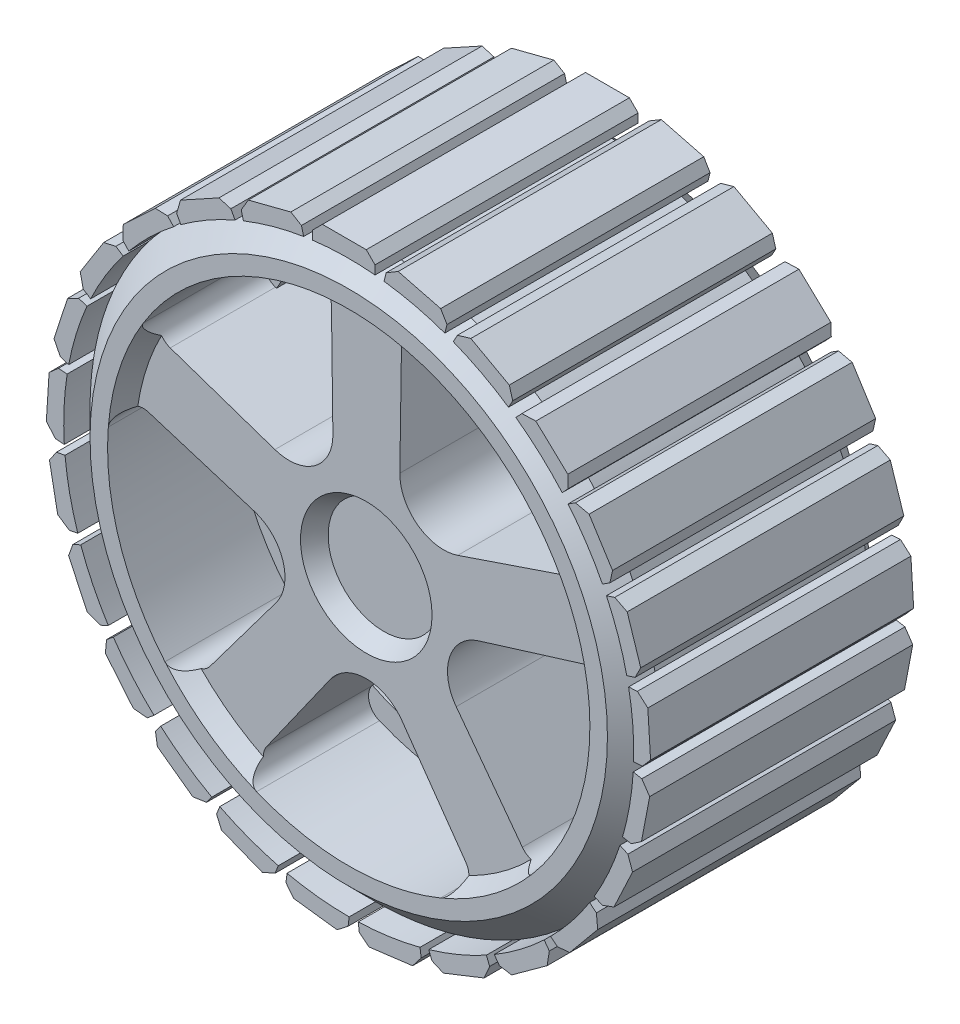
from build123d import *

# Parameters (mm, degrees)
SKETCH1_R           = 32.5
BOSS_EXTRUDE1_DEPTH = 15
CUT_EXTRUDE1_DEPTH  = 31
FILLET1_R           = 2
SKETCH5_R           = 27.5
CUT_EXTRUDE2_DEPTH  = 2
CUT_EXTRUDE2_TAPER  = 30
SKETCH7_R           = 7.5
CUT_EXTRUDE3_DEPTH  = 2
CUT_EXTRUDE3_TAPER  = 30
CHAMFER1_SIZE       = 3
SKETCH9_R           = 30
SKETCH9_R_2         = 25
BOSS_EXTRUDE2_DEPTH = 1
BOSS_EXTRUDE3_DEPTH = 15
SKETCH11_R          = 5
BOSS_EXTRUDE4_DEPTH = 4
SKETCH12_R          = 3
CUT_EXTRUDE4_DEPTH  = 10


with BuildPart() as part:
    # Sketch1 → Boss-Extrude1 (new body, symmetric)
    with BuildSketch(Plane.XY):
        Circle(SKETCH1_R)
    extrude(amount=BOSS_EXTRUDE1_DEPTH, both=True)

    # Sketch3 → Cut-Extrude1 (cut, through all)
    with BuildSketch(Plane.XY.offset(15)):
        with BuildLine():
            ThreePointArc((-4, 27.207535721), (-16.144447194, 22.262228657), (-24.618236097, 12.255302993))
            Line((-24.618236097, 12.255302993), (-10.420721182, 7.410922649))
            ThreePointArc((-10.420721182, 7.410922649), (-5.870708071, 8.095355875), (-3.806478173, 12.207535721))
            Line((-3.806478173, 12.207535721), (-4, 27.207535721))
        make_face()
        with BuildLine():
            Line((-12.786322839, 0.152160127), (-27.111972117, 4.603364848))
            ThreePointArc((-27.111972117, 4.603364848), (-26.16154618, -8.474874719), (-19.262939097, -19.626236964))
            Line((-19.262939097, -19.626236964), (-10.268386216, -7.620593742))
            ThreePointArc((-10.268386216, -7.620593742), (-9.51328952, -3.081772625), (-12.786322839, 0.152160127))
        make_face()
        with BuildLine():
            Line((-4.095903933, -12.113495591), (-12.75612027, -24.362499782))
            ThreePointArc((-12.75612027, -24.362499782), (-0.024277543, -27.499989284), (12.713085012, -24.384984508))
            Line((12.713085012, -24.384984508), (4.074509491, -12.120708596))
            ThreePointArc((4.074509491, -12.120708596), (-0.008828197, -9.999996103), (-4.095903933, -12.113495591))
        make_face()
        with BuildLine():
            ThreePointArc((27.5, 0), (27.404849824, 2.285652233), (27.120057736, 4.555487723))
            Line((27.120057736, 4.555487723), (12.786571569, 0.129583862))
            ThreePointArc((12.786571569, 0.129583862), (9.507833394, -3.098564854), (10.254914994, -7.638712124))
            Line((10.254914994, -7.638712124), (19.228256225, -19.660217764))
            ThreePointArc((19.228256225, -19.660217764), (25.347850463, -10.664730512), (27.5, 0))
        make_face()
        with BuildLine():
            ThreePointArc((24.639836162, 12.211816978), (16.183729084, 22.233688694), (4.048032445, 27.200430756))
            Line((4.048032445, 27.200430756), (3.828026338, 12.200795827))
            ThreePointArc((3.828026338, 12.200795827), (5.884992394, 8.084977707), (10.433789951, 7.392511868))
            Line((10.433789951, 7.392511868), (24.639836162, 12.211816978))
        make_face()
    extrude(amount=-CUT_EXTRUDE1_DEPTH, mode=Mode.SUBTRACT)

    # Fillet1
    fillet1_edges = [part.edges().sort_by_distance(p)[0] for p in [
        (12.713085012, -24.384984508, 0),
        (-12.75612027, -24.362499782, 0),
        (-19.262939097, -19.626236964, 0),
        (-27.111972117, 4.603364848, 0),
        (27.120057736, 4.555487723, 0),
        (19.228256225, -19.660217764, 0),
        (4.048032445, 27.200430756, 0),
        (24.639836162, 12.211816978, 0),
        (-24.618236097, 12.255302993, 0),
        (-4, 27.207535721, 0),
    ]]
    fillet(fillet1_edges, radius=FILLET1_R)

    # Sketch5 → Cut-Extrude2 (cut)
    with BuildSketch(Plane.XY.offset(15)):
        Circle(SKETCH5_R)
    cut_extrude2 = extrude(amount=-CUT_EXTRUDE2_DEPTH, taper=CUT_EXTRUDE2_TAPER, mode=Mode.SUBTRACT)

    # Sketch7 → Cut-Extrude3 (cut)
    with BuildSketch(Plane.XY.offset(13)):
        Circle(SKETCH7_R)
    cut_extrude3 = extrude(amount=-CUT_EXTRUDE3_DEPTH, taper=CUT_EXTRUDE3_TAPER, mode=Mode.SUBTRACT)

    # Mirror1: Cut-Extrude2, Cut-Extrude3 across plane
    add(cut_extrude2.mirror(Plane.XY), mode=Mode.SUBTRACT)
    add(cut_extrude3.mirror(Plane.XY), mode=Mode.SUBTRACT)

    # Chamfer1
    chamfer1_edges = [part.edges().sort_by_distance(p)[0] for p in [
        (-32.5, 0, -15),
        (-32.5, 0, 15),
    ]]
    chamfer(chamfer1_edges, length=CHAMFER1_SIZE)

    # Sketch9 → Boss-Extrude2 (add, symmetric)
    with BuildSketch(Plane.XY):
        Circle(SKETCH9_R)
        Circle(SKETCH9_R_2, mode=Mode.SUBTRACT)
    extrude(amount=BOSS_EXTRUDE2_DEPTH, both=True)

    # Sketch10 → Boss-Extrude3 (add, symmetric)
    with BuildSketch(Plane.XY):
        with BuildLine():
            Line((-4.12394956, 32.237292691), (-4.12394956, 33.237292691))
            Line((-4.12394956, 33.237292691), (-3, 34.361242251))
            Line((-3, 34.361242251), (2, 34.361242251))
            Line((2, 34.361242251), (3, 33.361242251))
            Line((3, 33.361242251), (3, 32.361242251))
            ThreePointArc((3, 32.361242251), (-0.565381753, 32.495081835), (-4.12394956, 32.237292691))
        make_face()
        with BuildLine():
            Line((4.022700581, 32.250083411), (4.271390468, 33.218666572))
            Line((4.271390468, 33.218666572), (5.639543975, 34.027790301))
            Line((5.639543975, 34.027790301), (10.48245978, 32.784340865))
            Line((10.48245978, 32.784340865), (11.202353054, 31.567067817))
            Line((11.202353054, 31.567067817), (10.953663167, 30.598484656))
            ThreePointArc((10.953663167, 30.598484656), (7.533578989, 31.614793809), (4.022700581, 32.250083411))
        make_face()
        with BuildLine():
            Line((11.916589649, 30.236482784), (12.398343324, 31.112789464))
            Line((12.398343324, 31.112789464), (13.924734661, 31.556247141))
            Line((13.924734661, 31.556247141), (18.306268061, 29.147478771))
            Line((18.306268061, 29.147478771), (18.700821067, 27.789418416))
            Line((18.700821067, 27.789418416), (18.219067393, 26.913111736))
            ThreePointArc((18.219067393, 26.913111736), (15.159177257, 28.748032017), (11.916589649, 30.236482784))
        make_face()
        with BuildLine():
            Line((19.061715564, 26.323012741), (19.74626267, 27.051981368))
            Line((19.74626267, 27.051981368), (21.334983056, 27.101908918))
            Line((21.334983056, 27.101908918), (24.979826194, 23.679173388))
            Line((24.979826194, 23.679173388), (25.024247715, 22.265657655))
            Line((25.024247715, 22.265657655), (24.339700609, 21.536689027))
            ThreePointArc((24.339700609, 21.536689027), (21.832268667, 24.074925646), (19.061715564, 26.323012741))
        make_face()
        with BuildLine():
            Line((25.009123786, 20.755570998), (25.853451712, 21.291397793))
            Line((25.853451712, 21.291397793), (27.404676002, 20.944658083))
            Line((27.404676002, 20.944658083), (30.083809977, 16.723018456))
            Line((30.083809977, 16.723018456), (29.775308847, 15.342863735))
            Line((29.775308847, 15.342863735), (28.930980921, 14.80703694))
            ThreePointArc((28.930980921, 14.80703694), (27.133558342, 17.889103155), (25.009123786, 20.755570998))
        make_face()
        with BuildLine():
            Line((29.385116783, 13.883980396), (30.3361733, 14.19299739))
            Line((30.3361733, 14.19299739), (31.752432367, 13.471377352))
            Line((31.752432367, 13.471377352), (33.297517339, 8.716094771))
            Line((33.297517339, 8.716094771), (32.655477817, 7.45602126))
            Line((32.655477817, 7.45602126), (31.704421301, 7.147004266))
            ThreePointArc((31.704421301, 7.147004266), (30.729946757, 10.579242521), (29.385116783, 13.883980396))
        make_face()
        with BuildLine():
            Line((31.914734822, 6.140008244), (32.912761551, 6.202798763))
            Line((32.912761551, 6.202798763), (34.105066629, 5.151640438))
            Line((34.105066629, 5.151640438), (34.419019227, 0.161506796))
            Line((34.419019227, 0.161506796), (33.483783018, -0.899310452))
            Line((33.483783018, -0.899310452), (32.48575629, -0.962100972))
            ThreePointArc((32.48575629, -0.962100972), (32.3954596, 2.604649172), (31.914734822, 6.140008244))
        make_face()
        with BuildLine():
            Line((32.439032698, -1.989763208), (33.421319949, -2.177144522))
            Line((33.421319949, -2.177144522), (34.314754126, -3.491792992))
            Line((34.314754126, -3.491792992), (33.377847553, -8.403229245))
            Line((33.377847553, -8.403229245), (32.208178987, -9.198135181))
            Line((32.208178987, -9.198135181), (31.225891737, -9.010753867))
            ThreePointArc((31.225891737, -9.010753867), (32.025446574, -5.533603864), (32.439032698, -1.989763208))
        make_face()
        with BuildLine():
            Line((30.925066847, -9.994510519), (31.829893899, -10.420289811))
            Line((31.829893899, -10.420289811), (32.368319419, -11.915824225))
            Line((32.368319419, -11.915824225), (30.239422962, -16.439959488))
            Line((30.239422962, -16.439959488), (28.908816617, -16.919007249))
            Line((28.908816617, -16.919007249), (28.003989565, -16.493227957))
            ThreePointArc((28.003989565, -16.493227957), (29.643156959, -13.324160218), (30.925066847, -9.994510519))
        make_face()
        with BuildLine():
            Line((27.467965311, -17.371265977), (28.238478554, -18.008689967))
            Line((28.238478554, -18.008689967), (28.388064162, -19.5911404))
            Line((28.388064162, -19.5911404), (25.200944213, -23.443706614))
            Line((25.200944213, -23.443706614), (23.79300698, -23.576795867))
            Line((23.79300698, -23.576795867), (23.022493737, -22.939371877))
            ThreePointArc((23.022493737, -22.939371877), (25.398278772, -20.277510583), (27.467965311, -17.371265977))
        make_face()
        with BuildLine():
            Line((22.284950495, -23.656520907), (22.872735748, -24.465537901))
            Line((22.872735748, -24.465537901), (22.624082428, -26.035473172))
            Line((22.624082428, -26.035473172), (18.578997457, -28.974399433))
            Line((18.578997457, -28.974399433), (17.18219521, -28.753167691))
            Line((17.18219521, -28.753167691), (16.594409958, -27.944150697))
            ThreePointArc((16.594409958, -27.944150697), (19.557533321, -25.956750382), (22.284950495, -23.656520907))
        make_face()
        with BuildLine():
            Line((15.701690281, -28.455349626), (16.069814834, -29.385126111))
            Line((16.069814834, -29.385126111), (15.438546391, -30.843901412))
            Line((15.438546391, -30.843901412), (10.789663961, -32.684524176))
            Line((10.789663961, -32.684524176), (9.491762923, -32.122872243))
            Line((9.491762923, -32.122872243), (9.12363837, -31.193095757))
            ThreePointArc((9.12363837, -31.193095757), (12.487916124, -30.005032092), (15.701690281, -28.455349626))
        make_face()
        with BuildLine():
            Line((8.13183512, -31.466224076), (8.257168354, -32.458338777))
            Line((8.257168354, -32.458338777), (7.282949704, -33.714293892))
            Line((7.282949704, -33.714293892), (2.322376198, -34.340960059))
            Line((2.322376198, -34.340960059), (1.204928263, -33.474178592))
            Line((1.204928263, -33.474178592), (1.079595029, -32.48206389))
            ThreePointArc((1.079595029, -32.48206389), (4.63363723, -32.167987286), (8.13183512, -31.466224076))
        make_face()
        with BuildLine():
            Line((0.051026852, -32.499959942), (-0.074306382, -33.492074644))
            Line((-0.074306382, -33.492074644), (-1.330261497, -34.466293293))
            Line((-1.330261497, -34.466293293), (-6.290835003, -33.839627125))
            Line((-6.290835003, -33.839627125), (-7.157616471, -32.72217919))
            Line((-7.157616471, -32.72217919), (-7.032283237, -31.730064489))
            ThreePointArc((-7.032283237, -31.730064489), (-3.511790132, -32.309709532), (0.051026852, -32.499959942))
        make_face()
        with BuildLine():
            Line((-8.032987622, -31.4916038), (-8.401112175, -32.421380285))
            Line((-8.401112175, -32.421380285), (-9.859887476, -33.052648729))
            Line((-9.859887476, -33.052648729), (-14.508769905, -31.212025965))
            Line((-14.508769905, -31.212025965), (-15.070421838, -29.914124927))
            Line((-15.070421838, -29.914124927), (-14.702297285, -28.984348441))
            ThreePointArc((-14.702297285, -28.984348441), (-11.436558806, -30.421293902), (-8.032987622, -31.4916038))
        make_face()
        with BuildLine():
            Line((-15.61225994, -28.504514372), (-16.200045192, -29.313531366))
            Line((-16.200045192, -29.313531366), (-17.769980462, -29.562184685))
            Line((-17.769980462, -29.562184685), (-21.815065434, -26.623258424))
            Line((-21.815065434, -26.623258424), (-22.036297176, -25.226456177))
            Line((-22.036297176, -25.226456177), (-21.448511924, -24.417439183))
            ThreePointArc((-21.448511924, -24.417439183), (-18.642726428, -26.621396495), (-15.61225994, -28.504514372))
        make_face()
        with BuildLine():
            Line((-22.210556547, -23.726381474), (-22.98106979, -24.363805464))
            Line((-22.98106979, -24.363805464), (-24.563520223, -24.214219856))
            Line((-24.563520223, -24.214219856), (-27.750640172, -20.361653643))
            Line((-27.750640172, -20.361653643), (-27.617550919, -18.95371641))
            Line((-27.617550919, -18.95371641), (-26.847037676, -18.31629242))
            ThreePointArc((-26.847037676, -18.31629242), (-24.677502986, -21.148778838), (-22.210556547, -23.726381474))
        make_face()
        with BuildLine():
            Line((-27.413282203, -17.457432769), (-28.318109255, -17.88321206))
            Line((-28.318109255, -17.88321206), (-29.81364367, -17.34478654))
            Line((-29.81364367, -17.34478654), (-31.942540128, -12.820651278))
            Line((-31.942540128, -12.820651278), (-31.463492367, -11.490044934))
            Line((-31.463492367, -11.490044934), (-30.558665314, -11.064265642))
            ThreePointArc((-30.558665314, -11.064265642), (-29.161701274, -14.347305628), (-27.413282203, -17.457432769))
        make_face()
        with BuildLine():
            Line((-30.893530518, -10.091569358), (-31.875817769, -10.278950673))
            Line((-31.875817769, -10.278950673), (-33.190466238, -9.385516496))
            Line((-33.190466238, -9.385516496), (-34.127372811, -4.474080242))
            Line((-34.127372811, -4.474080242), (-33.332466875, -3.304411677))
            Line((-33.332466875, -3.304411677), (-32.350179624, -3.117030362))
            ThreePointArc((-32.350179624, -3.117030362), (-31.813562622, -6.64433844), (-30.893530518, -10.091569358))
        make_face()
        with BuildLine():
            Line((-32.432624693, -2.091615531), (-33.430651421, -2.028825012))
            Line((-33.430651421, -2.028825012), (-34.481809747, -0.836519933))
            Line((-34.481809747, -0.836519933), (-34.167857149, 4.153613709))
            Line((-34.167857149, 4.153613709), (-33.107039901, 5.088849918))
            Line((-33.107039901, 5.088849918), (-32.109013173, 5.026059399))
            ThreePointArc((-32.109013173, 5.026059399), (-32.466460828, 1.476116969), (-32.432624693, -2.091615531))
        make_face()
        with BuildLine():
            Line((-31.933857779, 6.039762192), (-32.884914295, 6.348779187))
            Line((-32.884914295, 6.348779187), (-33.606534334, 7.765038254))
            Line((-33.606534334, 7.765038254), (-32.061449362, 12.520320836))
            Line((-32.061449362, 12.520320836), (-30.801375851, 13.162360358))
            Line((-30.801375851, 13.162360358), (-29.850319335, 12.853343363))
            ThreePointArc((-29.850319335, 12.853343363), (-31.079371897, 9.50382252), (-31.933857779, 6.039762192))
        make_face()
        with BuildLine():
            Line((-29.428569137, 13.791639445), (-30.272897062, 14.32746624))
            Line((-30.272897062, 14.32746624), (-30.619636772, 15.87869053))
            Line((-30.619636772, 15.87869053), (-27.940502797, 20.100330158))
            Line((-27.940502797, 20.100330158), (-26.560348077, 20.408831288))
            Line((-26.560348077, 20.408831288), (-25.716020151, 19.873004493))
            ThreePointArc((-25.716020151, 19.873004493), (-27.739451728, 16.93436795), (-29.428569137, 13.791639445))
        make_face()
        with BuildLine():
            Line((-25.074175265, 20.676937268), (-25.758722371, 21.405905896))
            Line((-25.758722371, 21.405905896), (-25.708794821, 22.994626282))
            Line((-25.708794821, 22.994626282), (-22.063951684, 26.417361812))
            Line((-22.063951684, 26.417361812), (-20.650435951, 26.37294029))
            Line((-20.650435951, 26.37294029), (-19.965888845, 25.643971663))
            ThreePointArc((-19.965888845, 25.643971663), (-22.656559788, 23.300864761), (-25.074175265, 20.676937268))
        make_face()
        with BuildLine():
            Line((-19.144278744, 26.263027079), (-19.626032418, 27.139333759))
            Line((-19.626032418, 27.139333759), (-19.182574741, 28.665725096))
            Line((-19.182574741, 28.665725096), (-14.801041341, 31.074493467))
            Line((-14.801041341, 31.074493467), (-13.442980987, 30.679940461))
            Line((-13.442980987, 30.679940461), (-12.961227313, 29.803633781))
            ThreePointArc((-12.961227313, 29.803633781), (-16.150072871, 28.203282544), (-19.144278744, 26.263027079))
        make_face()
        with BuildLine():
            Line((-12.011476783, 30.19891431), (-12.26016667, 31.167497471))
            Line((-12.26016667, 31.167497471), (-11.451042942, 32.535650978))
            Line((-11.451042942, 32.535650978), (-6.608127136, 33.779100414))
            Line((-6.608127136, 33.779100414), (-5.390854088, 33.05920714))
            Line((-5.390854088, 33.05920714), (-5.1421642, 32.090623979))
            ThreePointArc((-5.1421642, 32.090623979), (-8.628817481, 31.333584361), (-12.011476783, 30.19891431))
        make_face()
    extrude(amount=BOSS_EXTRUDE3_DEPTH, both=True)

    # Sketch11 → Boss-Extrude4 (add)
    with BuildSketch(Plane(origin=(0, 0, -11), x_dir=(-1, 0, 0), z_dir=(0, 0, -1))):
        Circle(SKETCH11_R)
    extrude(amount=BOSS_EXTRUDE4_DEPTH)

    # Sketch12 → Cut-Extrude4 (cut)
    with BuildSketch(Plane(origin=(0, 0, -15), x_dir=(-1, 0, 0), z_dir=(0, 0, -1))):
        Circle(SKETCH12_R)
    extrude(amount=-CUT_EXTRUDE4_DEPTH, mode=Mode.SUBTRACT)


solid = part.part
